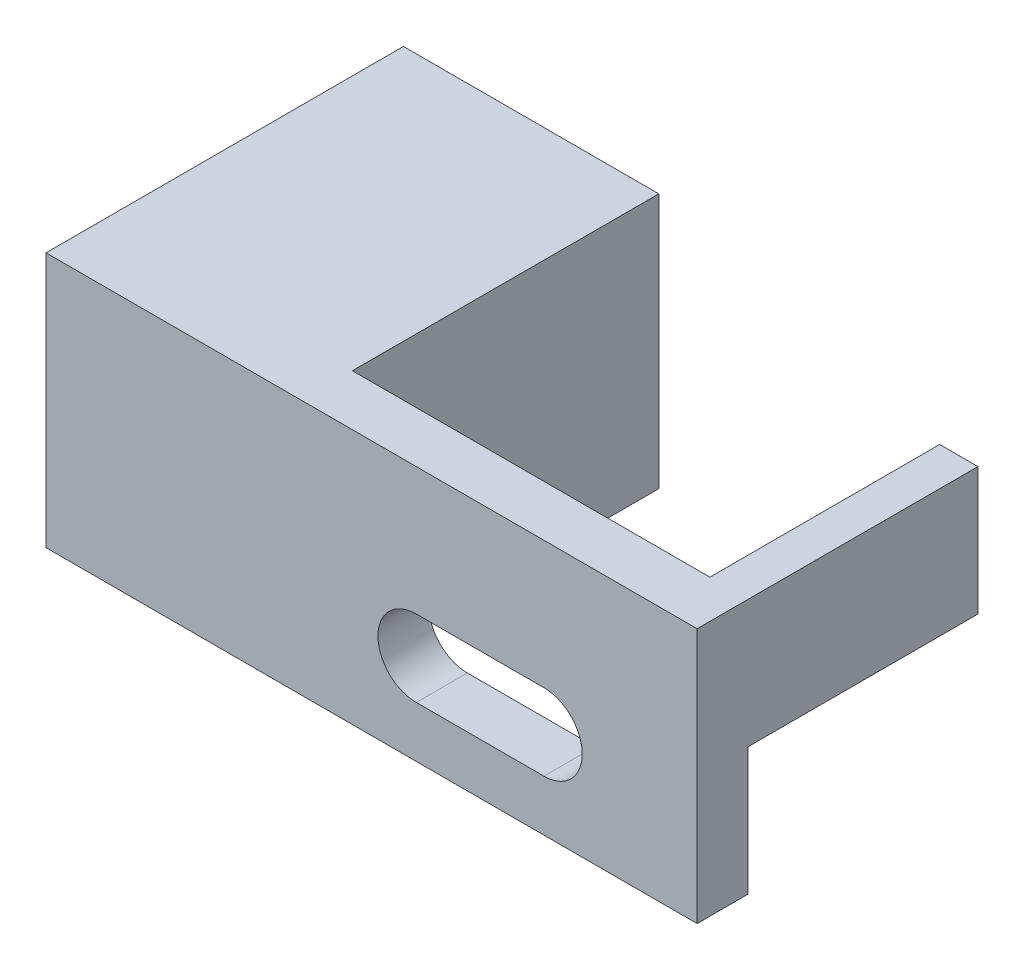
from build123d import *

# Parameters (mm, degrees)
BOSS_EXTRUDE1_DEPTH = 10
CUT_EXTRUDE1_REACH  = 3.5
SKETCH2_W           = 9
SKETCH2_H           = 5
CUT_EXTRUDE2_REACH  = 4


with BuildPart() as part:
    # Sketch1 → Boss-Extrude1 (new body)
    with BuildSketch(Plane(origin=(0, 0, 0), x_dir=(1, 0, 0), z_dir=(0, 1, 0))):
        Polygon((0, 0), (25.5, 0), (25.5, 11), (24, 11), (24, 2), (10, 2), (10, 14), (0, 14), align=None)
    extrude(amount=BOSS_EXTRUDE1_DEPTH)

    # Sketch2 → Cut-Extrude1 (cut, up to next)
    with BuildSketch(Plane.ZY.offset(-24), mode=Mode.PRIVATE) as cut_extrude1_sk1:
        with Locations((-6.5, 2.5)):
            Rectangle(SKETCH2_W, SKETCH2_H)
    cut_extrude1_tool1 = extrude(cut_extrude1_sk1.sketch, amount=-CUT_EXTRUDE1_REACH, mode=Mode.PRIVATE) & part.part
    add(cut_extrude1_tool1.solids().sort_by_distance((24, 2.5, -6.5))[0], mode=Mode.SUBTRACT)

    # Sketch3 → Cut-Extrude2 (cut, up to next)
    with BuildSketch(Plane(origin=(0, 0, -2), x_dir=(-1, 0, 0), z_dir=(0, 0, -1)), mode=Mode.PRIVATE) as cut_extrude2_sk1:
        with BuildLine():
            Line((-19.5, 5), (-14.5, 5))
            ThreePointArc((-14.5, 5), (-13, 3.5), (-14.5, 2))
            Line((-14.5, 2), (-19.5, 2))
            ThreePointArc((-19.5, 2), (-21, 3.5), (-19.5, 5))
        make_face()
    cut_extrude2_tool1 = extrude(cut_extrude2_sk1.sketch, amount=-CUT_EXTRUDE2_REACH, mode=Mode.PRIVATE) & part.part
    add(cut_extrude2_tool1.solids().sort_by_distance((17, 3.5, -2))[0], mode=Mode.SUBTRACT)


solid = part.part
